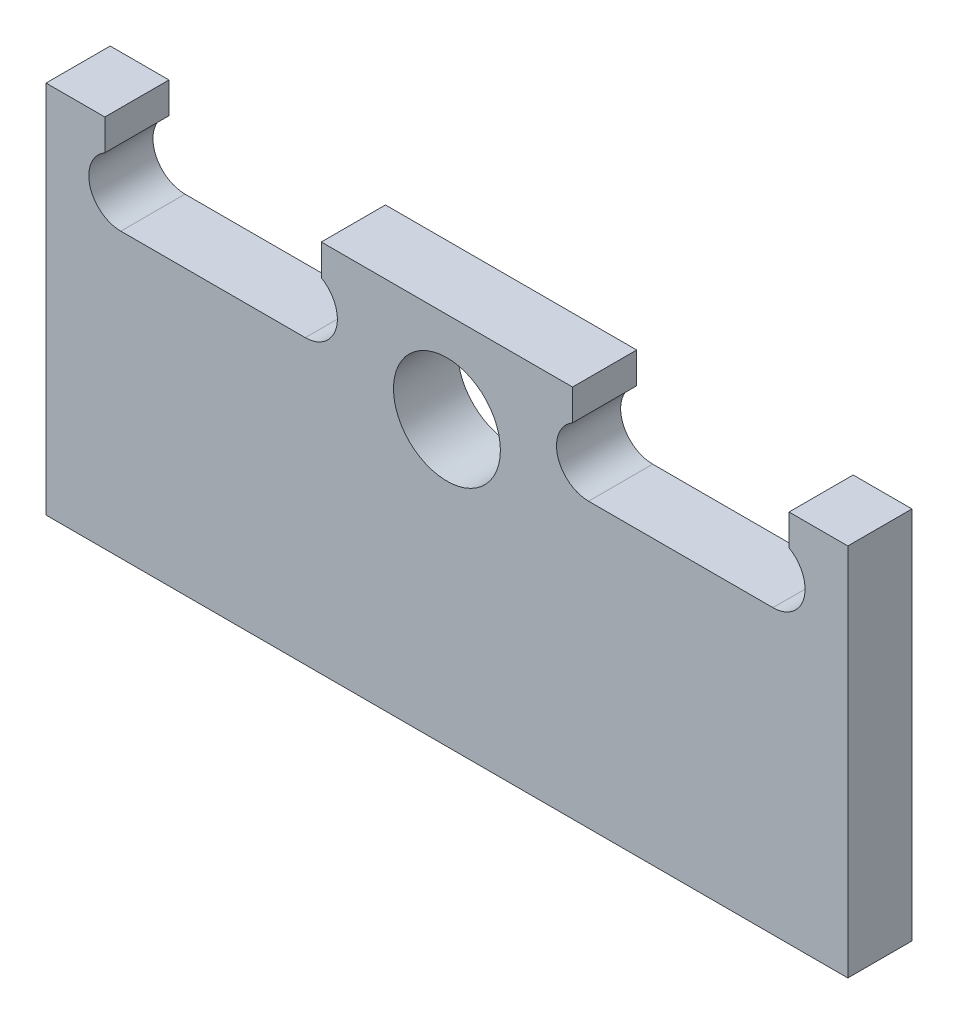
from build123d import *

# Parameters (mm, degrees)
CROQUIS1_R              = 10
SALIENTE_EXTRUIR1_DEPTH = 12


with BuildPart() as part:
    # Croquis1 → Saliente-Extruir1 (new body)
    with BuildSketch(Plane.XY):
        with BuildLine():
            Line((0, 0), (0, 70))
            Line((0, 70), (11, 70))
            Line((11, 70), (11, 64.196152423))
            ThreePointArc((11, 64.196152423), (8.204445042, 57.447085729), (14, 53))
            Line((14, 53), (48.5, 53))
            ThreePointArc((48.5, 53), (54.295554958, 57.447085729), (51.5, 64.196152423))
            Line((51.5, 64.196152423), (51.5, 70))
            Line((51.5, 70), (98.5, 70))
            Line((98.5, 70), (98.5, 64.196152423))
            ThreePointArc((98.5, 64.196152423), (95.704445042, 57.447085729), (101.5, 53))
            Line((101.5, 53), (136, 53))
            ThreePointArc((136, 53), (141.795554958, 57.447085729), (139, 64.196152423))
            Line((139, 64.196152423), (139, 70))
            Line((139, 70), (150, 70))
            Line((150, 70), (150, 0))
            Line((150, 0), (0, 0))
        make_face()
        with Locations((75, 53)):
            Circle(CROQUIS1_R, mode=Mode.SUBTRACT)
    extrude(amount=SALIENTE_EXTRUIR1_DEPTH)


solid = part.part
